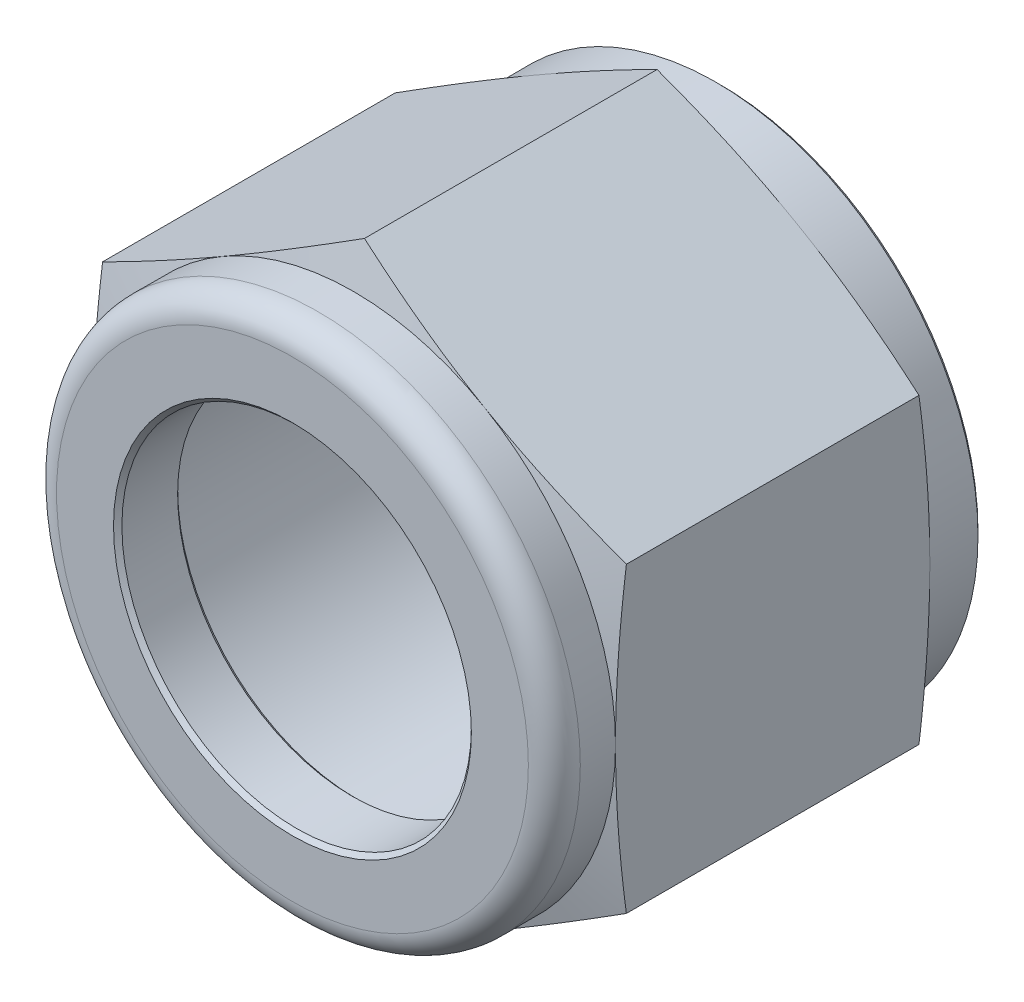
from build123d import *

# Parameters (mm, degrees)
BOSS_EXTRUDE1_DEPTH = 25.9334
FILLET1_R           = 1.5748
CHAMFER1_SIZE       = 0.254
CHAMFER2_SIZE       = 0.254


with BuildPart() as part:
    # Sketch1 → Boss-Extrude1 (new body)
    with BuildSketch(Plane.XY):
        Polygon((0, 18.330871047), (-15.875, 9.165435523), (-15.875, -9.165435523), (0, -18.330871047), (15.875, -9.165435523), (15.875, 9.165435523), align=None)
    extrude(amount=BOSS_EXTRUDE1_DEPTH)

    # Sketch2 → Cut-Revolve1 (revolve, cut)
    with BuildSketch(Plane(origin=(0, 0, 0), x_dir=(0, 0, -1), z_dir=(1, 0, 0))):
        Polygon((-25.9334, 20.786742094), (-25.9334, 15.875), (-22.225, 15.875), (-21.566951336, 18.330871047), (-3.833048664, 18.330871047), (-3.175, 15.875), (0, 15.875), (0, 20.786742094), align=None)
        with BuildLine():
            Line((-25.9334, 10.5918), (-25.9334, 0))
            Line((-25.9334, 0), (0, 0))
            Line((0, 0), (0, 12.720416378))
            Line((0, 12.720416378), (-21.7932, 12.720416378))
            ThreePointArc((-21.7932, 12.720416378), (-21.972805122, 12.6460215), (-22.0472, 12.466416378))
            Line((-22.0472, 12.466416378), (-22.0472, 10.5918))
            Line((-22.0472, 10.5918), (-25.9334, 10.5918))
        make_face()
    revolve(axis=Axis((0, 0, 0), (0, 0, 1)), mode=Mode.SUBTRACT)

    # Fillet1
    fillet1_edges = [part.edges().sort_by_distance(p)[0] for p in [
        (0, -15.875, 25.9334),
    ]]
    fillet(fillet1_edges, radius=FILLET1_R)

    # Chamfer1
    chamfer1_edges = [part.edges().sort_by_distance(p)[0] for p in [
        (0, -15.875, 0),
    ]]
    chamfer(chamfer1_edges, length=CHAMFER1_SIZE)

    # Chamfer2
    chamfer2_edges = [part.edges().sort_by_distance(p)[0] for p in [
        (0, -10.5918, 25.9334),
        (0, -10.5918, 22.0472),
    ]]
    chamfer(chamfer2_edges, length=CHAMFER2_SIZE)


solid = part.part
